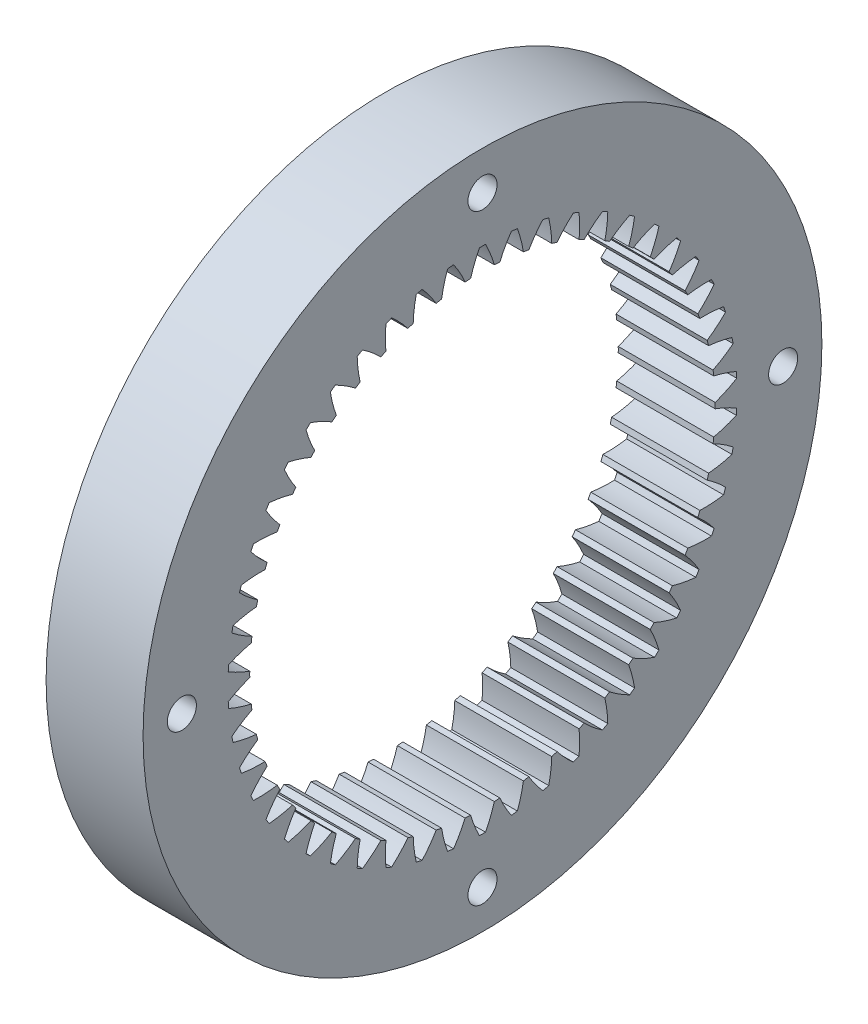
from build123d import *

# Parameters (mm, degrees)
BASPROSKE_W         = 10
BASPROSKE_H         = 6
TOOTHCUT_DEPTH      = 44.588989435
TEETHCUTS_COUNT     = 50
TEETHCUTS_ANGLE     = 352.8
SKETCH1_R           = 35
SKETCH1_R_2         = 30
BOSS_EXTRUDE1_DEPTH = 10
SKETCH2_R           = 1.5
CUT_EXTRUDE1_DEPTH  = 10


with BuildPart() as part:
    # BasProSke → Base-Revolve (revolve)
    with BuildSketch(Plane(origin=(0, 0, 0), x_dir=(1, 0, 0), z_dir=(0, 1, 0))):
        with Locations((5, 27)):
            Rectangle(BASPROSKE_W, BASPROSKE_H)
    revolve(axis=Axis((-10, 0, 0), (1, 0, 0)))

    # TooCutSke → ToothCut (cut, through all)
    with BuildSketch(Plane(origin=(0, 0, 0), x_dir=(0, 0, -1), z_dir=(1, 0, 0))):
        with BuildLine():
            ThreePointArc((1.228249008, 23.943116955), (0.8277994, 25.118901547), (0.312635126, 26.249138277))
            ThreePointArc((0.312635126, 26.249138277), (0, 26.251), (-0.312635126, 26.249138277))
            ThreePointArc((-0.312635126, 26.249138277), (-0.8277994, 25.118901547), (-1.228249008, 23.943116955))
            ThreePointArc((-1.228249008, 23.943116955), (0, 23.9746), (1.228249008, 23.943116955))
        make_face()
    toothcut = extrude(amount=TOOTHCUT_DEPTH, mode=Mode.SUBTRACT)

    # TeethCuts: ToothCut ×50 about axis
    teethcuts_axis = Axis((-10, 0, 0), (1, 0, 0))
    for i in range(1, TEETHCUTS_COUNT):
        add(toothcut.rotate(teethcuts_axis, i * TEETHCUTS_ANGLE / (TEETHCUTS_COUNT - 1)), mode=Mode.SUBTRACT)

    # Sketch1 → Boss-Extrude1 (add)
    with BuildSketch(Plane(origin=(10, 0, 0), x_dir=(0, 0, -1), z_dir=(1, 0, 0))):
        Circle(SKETCH1_R)
        Circle(SKETCH1_R_2, mode=Mode.SUBTRACT)
    extrude(amount=-BOSS_EXTRUDE1_DEPTH)

    # Sketch2 → Cut-Extrude1 (cut)
    with BuildSketch(Plane(origin=(10, 0, 0), x_dir=(0, 0, -1), z_dir=(1, 0, 0))):
        with Locations((31, 0)):
            Circle(SKETCH2_R)
        with Locations((0, 31)):
            Circle(SKETCH2_R)
        with Locations((0, -31)):
            Circle(SKETCH2_R)
        with Locations((-31, 0)):
            Circle(SKETCH2_R)
    extrude(amount=-CUT_EXTRUDE1_DEPTH, mode=Mode.SUBTRACT)


solid = part.part
